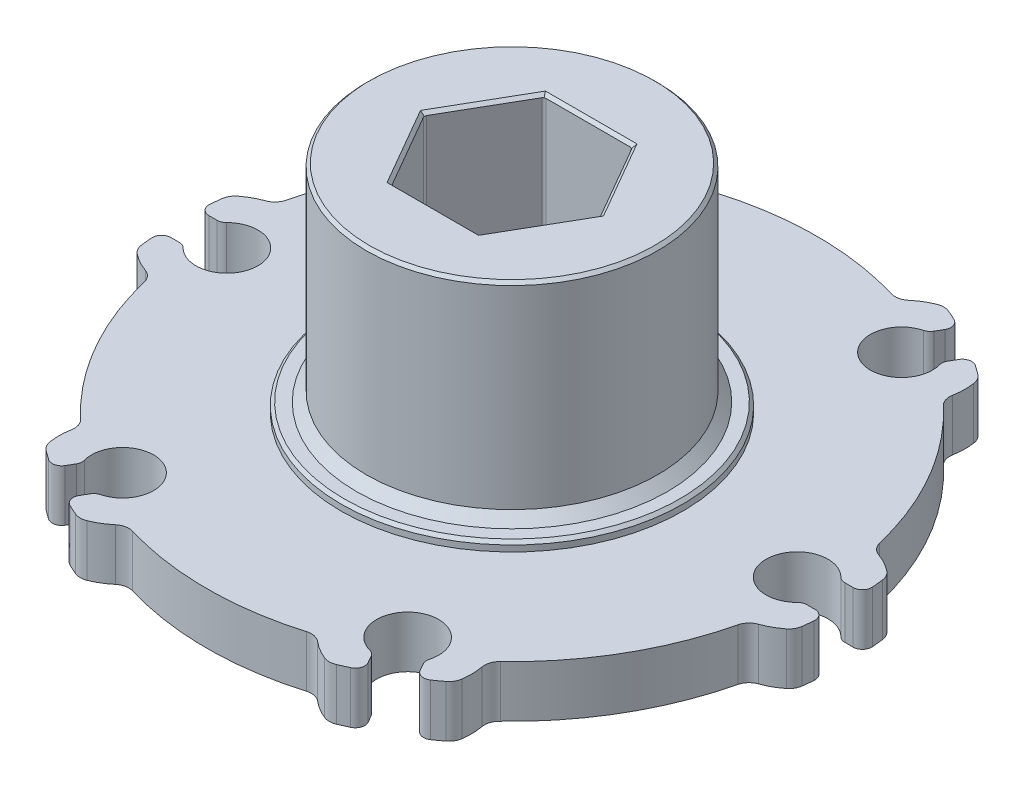
from build123d import *

# Parameters (mm, degrees)
SKETCH1_W           = 27.7876
SKETCH1_H           = 4.318
CUT_EXTRUDE1_DEPTH  = 5.318
CUT_EXTRUDE2_DEPTH  = 5.318
CUT_EXTRUDE3_DEPTH  = 5.318
CUT_EXTRUDE4_DEPTH  = 5.318
CUT_EXTRUDE5_DEPTH  = 5.318
CUT_EXTRUDE6_DEPTH  = 5.318
CUT_EXTRUDE7_DEPTH  = 5.318
CUT_EXTRUDE8_DEPTH  = 5.318
CUT_EXTRUDE9_DEPTH  = 5.318
CUT_EXTRUDE10_DEPTH = 5.318
CUT_EXTRUDE11_DEPTH = 5.318
CUT_EXTRUDE12_DEPTH = 5.318
SKETCH14_R          = 14.2748
BOSS_EXTRUDE1_DEPTH = 1.524
SKETCH15_R          = 9.23823544
BOSS_EXTRUDE2_DEPTH = 1.524
SKETCH16_R          = 14.2748
BOSS_EXTRUDE3_DEPTH = 0.762
SKETCH17_R          = 12.1666
BOSS_EXTRUDE4_DEPTH = 17.272
CUT_EXTRUDE13_DEPTH = 26.4
SKETCH19_W          = 2.5908
SKETCH19_H          = 4.318
SKETCH20_W          = 2.5908
SKETCH20_H          = 4.318
SKETCH21_W          = 2.5908
SKETCH21_H          = 4.318
SKETCH22_W          = 2.5908
SKETCH22_H          = 4.318
SKETCH23_W          = 2.5908
SKETCH23_H          = 4.318
SKETCH24_W          = 2.5908
SKETCH24_H          = 4.318
CHAMFER1_SIZE       = 0.254
CHAMFER2_SIZE       = 0.8128
FILLET1_R           = 0.254
FILLET2_R           = 0.7874
FILLET3_R           = 1.27


with BuildPart() as part:
    # Sketch1 → Revolve1 (revolve)
    with BuildSketch(Plane.XY):
        with Locations((13.8938, 5.207)):
            Rectangle(SKETCH1_W, SKETCH1_H)
    revolve(axis=Axis((0, 7.366, 0), (0, -1, 0)))

    # Sketch2 → Cut-Extrude1 (cut, through all)
    with BuildSketch(Plane(origin=(0, 7.366, 0), x_dir=(-1, 0, 0), z_dir=(0, 1, 0))):
        with BuildLine():
            Line((27.742216161, 1.5875), (25.859959008, 1.5875))
            ThreePointArc((25.859959008, 1.5875), (26.4033, 0), (25.859959008, -1.5875))
            Line((25.859959008, -1.5875), (27.742216161, -1.5875))
            ThreePointArc((27.742216161, -1.5875), (27.7876, 0), (27.742216161, 1.5875))
        make_face()
    extrude(amount=-CUT_EXTRUDE1_DEPTH, mode=Mode.SUBTRACT)

    # Sketch3 → Cut-Extrude2 (cut, through all)
    with BuildSketch(Plane(origin=(0, 7.366, 0), x_dir=(-1, 0, 0), z_dir=(0, 1, 0))):
        with BuildLine():
            ThreePointArc((27.521980347, -3.832924674), (26.332306318, -4.701290474), (24.95050128, -5.211190755))
            ThreePointArc((24.95050128, -5.211190755), (22.074034915, -12.74445), (16.988274218, -19.002172568))
            ThreePointArc((16.988274218, -19.002172568), (17.23759014, -20.453800974), (17.080400312, -21.918271806))
            ThreePointArc((17.080400312, -21.918271806), (24.06476751, -13.8938), (27.521980347, -3.832924674))
        make_face()
    extrude(amount=-CUT_EXTRUDE2_DEPTH, mode=Mode.SUBTRACT)

    # Sketch4 → Cut-Extrude3 (cut, through all)
    with BuildSketch(Plane(origin=(0, 7.366, 0), x_dir=(-1, 0, 0), z_dir=(0, 1, 0))):
        with BuildLine():
            Line((15.245923409, -23.231713952), (14.304794833, -21.601631442))
            ThreePointArc((14.304794833, -21.601631442), (13.20165, -22.865928544), (11.555164176, -23.189131442))
            Line((11.555164176, -23.189131442), (12.496292752, -24.819213952))
            ThreePointArc((12.496292752, -24.819213952), (13.8938, -24.06476751), (15.245923409, -23.231713952))
        make_face()
    extrude(amount=-CUT_EXTRUDE3_DEPTH, mode=Mode.SUBTRACT)

    # Sketch5 → Cut-Extrude4 (cut, through all)
    with BuildSketch(Plane(origin=(0, 7.366, 0), x_dir=(-1, 0, 0), z_dir=(0, 1, 0))):
        with BuildLine():
            ThreePointArc((10.441580035, -25.75119648), (9.094716178, -25.155091448), (7.962227062, -24.213363323))
            ThreePointArc((7.962227062, -24.213363323), (0, -25.4889), (-7.962227062, -24.213363323))
            ThreePointArc((-7.962227062, -24.213363323), (-9.094716178, -25.155091448), (-10.441580035, -25.75119648))
            ThreePointArc((-10.441580035, -25.75119648), (0, -27.7876), (10.441580035, -25.75119648))
        make_face()
    extrude(amount=-CUT_EXTRUDE4_DEPTH, mode=Mode.SUBTRACT)

    # Sketch6 → Cut-Extrude5 (cut, through all)
    with BuildSketch(Plane(origin=(0, 7.366, 0), x_dir=(-1, 0, 0), z_dir=(0, 1, 0))):
        with BuildLine():
            Line((-12.496292752, -24.819213952), (-11.555164176, -23.189131442))
            ThreePointArc((-11.555164176, -23.189131442), (-13.20165, -22.865928544), (-14.304794833, -21.601631442))
            Line((-14.304794833, -21.601631442), (-15.245923409, -23.231713952))
            ThreePointArc((-15.245923409, -23.231713952), (-13.8938, -24.06476751), (-12.496292752, -24.819213952))
        make_face()
    extrude(amount=-CUT_EXTRUDE5_DEPTH, mode=Mode.SUBTRACT)

    # Sketch7 → Cut-Extrude6 (cut, through all)
    with BuildSketch(Plane(origin=(0, 7.366, 0), x_dir=(-1, 0, 0), z_dir=(0, 1, 0))):
        with BuildLine():
            ThreePointArc((-17.080400312, -21.918271806), (-17.23759014, -20.453800974), (-16.988274218, -19.002172568))
            ThreePointArc((-16.988274218, -19.002172568), (-22.074034915, -12.74445), (-24.95050128, -5.211190755))
            ThreePointArc((-24.95050128, -5.211190755), (-26.332306318, -4.701290474), (-27.521980347, -3.832924674))
            ThreePointArc((-27.521980347, -3.832924674), (-24.06476751, -13.8938), (-17.080400312, -21.918271806))
        make_face()
    extrude(amount=-CUT_EXTRUDE6_DEPTH, mode=Mode.SUBTRACT)

    # Sketch8 → Cut-Extrude7 (cut, through all)
    with BuildSketch(Plane(origin=(0, 7.366, 0), x_dir=(-1, 0, 0), z_dir=(0, 1, 0))):
        with BuildLine():
            Line((-27.742216161, -1.5875), (-25.859959008, -1.5875))
            ThreePointArc((-25.859959008, -1.5875), (-26.4033, 0), (-25.859959008, 1.5875))
            Line((-25.859959008, 1.5875), (-27.742216161, 1.5875))
            ThreePointArc((-27.742216161, 1.5875), (-27.7876, 0), (-27.742216161, -1.5875))
        make_face()
    extrude(amount=-CUT_EXTRUDE7_DEPTH, mode=Mode.SUBTRACT)

    # Sketch9 → Cut-Extrude8 (cut, through all)
    with BuildSketch(Plane(origin=(0, 7.366, 0), x_dir=(-1, 0, 0), z_dir=(0, 1, 0))):
        with BuildLine():
            ThreePointArc((-27.521980347, 3.832924674), (-26.332306318, 4.701290474), (-24.95050128, 5.211190755))
            ThreePointArc((-24.95050128, 5.211190755), (-22.074034915, 12.74445), (-16.988274218, 19.002172568))
            ThreePointArc((-16.988274218, 19.002172568), (-17.23759014, 20.453800974), (-17.080400312, 21.918271806))
            ThreePointArc((-17.080400312, 21.918271806), (-24.06476751, 13.8938), (-27.521980347, 3.832924674))
        make_face()
    extrude(amount=-CUT_EXTRUDE8_DEPTH, mode=Mode.SUBTRACT)

    # Sketch10 → Cut-Extrude9 (cut, through all)
    with BuildSketch(Plane(origin=(0, 7.366, 0), x_dir=(-1, 0, 0), z_dir=(0, 1, 0))):
        with BuildLine():
            Line((-15.245923409, 23.231713952), (-14.304794833, 21.601631442))
            ThreePointArc((-14.304794833, 21.601631442), (-13.20165, 22.865928544), (-11.555164176, 23.189131442))
            Line((-11.555164176, 23.189131442), (-12.496292752, 24.819213952))
            ThreePointArc((-12.496292752, 24.819213952), (-13.8938, 24.06476751), (-15.245923409, 23.231713952))
        make_face()
    extrude(amount=-CUT_EXTRUDE9_DEPTH, mode=Mode.SUBTRACT)

    # Sketch11 → Cut-Extrude10 (cut, through all)
    with BuildSketch(Plane(origin=(0, 7.366, 0), x_dir=(-1, 0, 0), z_dir=(0, 1, 0))):
        with BuildLine():
            ThreePointArc((-10.441580035, 25.75119648), (-9.094716178, 25.155091448), (-7.962227062, 24.213363323))
            ThreePointArc((-7.962227062, 24.213363323), (0, 25.4889), (7.962227062, 24.213363323))
            ThreePointArc((7.962227062, 24.213363323), (9.094716178, 25.155091448), (10.441580035, 25.75119648))
            ThreePointArc((10.441580035, 25.75119648), (0, 27.7876), (-10.441580035, 25.75119648))
        make_face()
    extrude(amount=-CUT_EXTRUDE10_DEPTH, mode=Mode.SUBTRACT)

    # Sketch12 → Cut-Extrude11 (cut, through all)
    with BuildSketch(Plane(origin=(0, 7.366, 0), x_dir=(-1, 0, 0), z_dir=(0, 1, 0))):
        with BuildLine():
            Line((12.496292752, 24.819213952), (11.555164176, 23.189131442))
            ThreePointArc((11.555164176, 23.189131442), (13.20165, 22.865928544), (14.304794833, 21.601631442))
            Line((14.304794833, 21.601631442), (15.245923409, 23.231713952))
            ThreePointArc((15.245923409, 23.231713952), (13.8938, 24.06476751), (12.496292752, 24.819213952))
        make_face()
    extrude(amount=-CUT_EXTRUDE11_DEPTH, mode=Mode.SUBTRACT)

    # Sketch13 → Cut-Extrude12 (cut, through all)
    with BuildSketch(Plane(origin=(0, 7.366, 0), x_dir=(-1, 0, 0), z_dir=(0, 1, 0))):
        with BuildLine():
            ThreePointArc((17.080400312, 21.918271806), (17.23759014, 20.453800974), (16.988274218, 19.002172568))
            ThreePointArc((16.988274218, 19.002172568), (22.074034915, 12.74445), (24.95050128, 5.211190755))
            ThreePointArc((24.95050128, 5.211190755), (26.332306318, 4.701290474), (27.521980347, 3.832924674))
            ThreePointArc((27.521980347, 3.832924674), (24.06476751, 13.8938), (17.080400312, 21.918271806))
        make_face()
    extrude(amount=-CUT_EXTRUDE12_DEPTH, mode=Mode.SUBTRACT)

    # Sketch14 → Boss-Extrude1 (add)
    with BuildSketch(Plane.XZ.offset(-3.048)):
        Circle(SKETCH14_R)
    extrude(amount=BOSS_EXTRUDE1_DEPTH)

    # Sketch15 → Boss-Extrude2 (add)
    with BuildSketch(Plane.XZ.offset(-1.524)):
        Circle(SKETCH15_R)
    extrude(amount=BOSS_EXTRUDE2_DEPTH)

    # Sketch16 → Boss-Extrude3 (add)
    with BuildSketch(Plane(origin=(0, 7.366, 0), x_dir=(-1, 0, 0), z_dir=(0, 1, 0))):
        Circle(SKETCH16_R)
    extrude(amount=BOSS_EXTRUDE3_DEPTH)

    # Sketch17 → Boss-Extrude4 (add)
    with BuildSketch(Plane(origin=(0, 8.128, 0), x_dir=(-1, 0, 0), z_dir=(0, 1, 0))):
        Circle(SKETCH17_R)
    extrude(amount=BOSS_EXTRUDE4_DEPTH)

    # Sketch18 → Cut-Extrude13 (cut, through all)
    with BuildSketch(Plane(origin=(0, 25.4, 0), x_dir=(-1, 0, 0), z_dir=(0, 1, 0))):
        Polygon((-3.673506558, -6.3627), (3.673506558, -6.3627), (7.347013116, 0), (3.673506558, 6.3627), (-3.673506558, 6.3627), (-7.347013116, 0), align=None)
    extrude(amount=-CUT_EXTRUDE13_DEPTH, mode=Mode.SUBTRACT)

    # Sketch19 → Cut-Revolve1 (revolve, cut)
    with BuildSketch(Plane(origin=(0, 0, 0), x_dir=(-1, 0, 0), z_dir=(0, 0, -1))):
        with Locations((22.5171, 5.207)):
            Rectangle(SKETCH19_W, SKETCH19_H)
    revolve(axis=Axis((-23.8125, 3.048, 0), (0, 1, 0)), mode=Mode.SUBTRACT)

    # Sketch20 → Cut-Revolve2 (revolve, cut)
    with BuildSketch(Plane(origin=(0, 0, -20.622229928), x_dir=(-1, 0, 0), z_dir=(0, 0, -1))):
        with Locations((10.61085, 5.207)):
            Rectangle(SKETCH20_W, SKETCH20_H)
    revolve(axis=Axis((-11.90625, 3.048, -20.622229928), (0, 1, 0)), mode=Mode.SUBTRACT)

    # Sketch21 → Cut-Revolve3 (revolve, cut)
    with BuildSketch(Plane(origin=(0, 0, -20.622229928), x_dir=(-1, 0, 0), z_dir=(0, 0, -1))):
        with Locations((-13.20165, 5.207)):
            Rectangle(SKETCH21_W, SKETCH21_H)
    revolve(axis=Axis((11.90625, 3.048, -20.622229928), (0, 1, 0)), mode=Mode.SUBTRACT)

    # Sketch22 → Cut-Revolve4 (revolve, cut)
    with BuildSketch(Plane(origin=(0, 0, 0), x_dir=(-1, 0, 0), z_dir=(0, 0, -1))):
        with Locations((-25.1079, 5.207)):
            Rectangle(SKETCH22_W, SKETCH22_H)
    revolve(axis=Axis((23.8125, 3.048, 0), (0, 1, 0)), mode=Mode.SUBTRACT)

    # Sketch23 → Cut-Revolve5 (revolve, cut)
    with BuildSketch(Plane(origin=(0, 0, 20.622229928), x_dir=(-1, 0, 0), z_dir=(0, 0, -1))):
        with Locations((-13.20165, 5.207)):
            Rectangle(SKETCH23_W, SKETCH23_H)
    revolve(axis=Axis((11.90625, 3.048, 20.622229928), (0, 1, 0)), mode=Mode.SUBTRACT)

    # Sketch24 → Cut-Revolve6 (revolve, cut)
    with BuildSketch(Plane(origin=(0, 0, 20.622229928), x_dir=(-1, 0, 0), z_dir=(0, 0, -1))):
        with Locations((10.61085, 5.207)):
            Rectangle(SKETCH24_W, SKETCH24_H)
    revolve(axis=Axis((-11.90625, 3.048, 20.622229928), (0, 1, 0)), mode=Mode.SUBTRACT)

    # Chamfer1
    chamfer1_edges = [part.edges().sort_by_distance(p)[0] for p in [
        (-14.2748, 1.524, 0),
        (-9.23823544, 0, 0),
        (14.2748, 8.128, 0),
        (12.1666, 25.4, 0),
        (5.510259837, 0, -3.18135),
        (5.510259837, 0, 3.18135),
        (0, 0, 6.3627),
        (-5.510259837, 0, 3.18135),
        (-5.510259837, 0, -3.18135),
        (0, 0, -6.3627),
        (5.510259837, 25.4, -3.18135),
        (0, 25.4, -6.3627),
        (-5.510259837, 25.4, -3.18135),
        (-5.510259837, 25.4, 3.18135),
        (0, 25.4, 6.3627),
        (5.510259837, 25.4, 3.18135),
    ]]
    chamfer(chamfer1_edges, length=CHAMFER1_SIZE)

    # Chamfer2
    chamfer2_edges = [part.edges().sort_by_distance(p)[0] for p in [
        (12.1666, 8.128, 0),
    ]]
    chamfer(chamfer2_edges, length=CHAMFER2_SIZE)

    # Fillet1
    fillet1_edges = [part.edges().sort_by_distance(p)[0] for p in [
        (3.673506558, 12.7, -6.3627),
        (7.347013116, 12.7, 0),
        (-3.673506558, 12.7, -6.3627),
        (-7.347013116, 12.7, 0),
        (-3.673506558, 12.7, 6.3627),
        (3.673506558, 12.7, 6.3627),
    ]]
    fillet(fillet1_edges, radius=FILLET1_R)

    # Fillet2
    fillet2_edges = [part.edges().sort_by_distance(p)[0] for p in [
        (27.742216161, 5.207, -1.5875),
        (27.742216161, 5.207, 1.5875),
        (25.859959008, 5.207, 1.5875),
        (25.859959008, 5.207, -1.5875),
        (-27.742216161, 5.207, 1.5875),
        (-27.742216161, 5.207, -1.5875),
        (-25.859959008, 5.207, -1.5875),
        (-25.859959008, 5.207, 1.5875),
        (15.245923409, 5.207, 23.231713952),
        (12.496292752, 5.207, 24.819213952),
        (11.555164176, 5.207, 23.189131442),
        (14.304794833, 5.207, 21.601631442),
        (-12.496292752, 5.207, 24.819213952),
        (-15.245923409, 5.207, 23.231713952),
        (-14.304794833, 5.207, 21.601631442),
        (-11.555164176, 5.207, 23.189131442),
        (-15.245923409, 5.207, -23.231713952),
        (-12.496292752, 5.207, -24.819213952),
        (-11.555164176, 5.207, -23.189131442),
        (-14.304794833, 5.207, -21.601631442),
        (12.496292752, 5.207, -24.819213952),
        (15.245923409, 5.207, -23.231713952),
        (14.304794833, 5.207, -21.601631442),
        (11.555164176, 5.207, -23.189131442),
    ]]
    fillet(fillet2_edges, radius=FILLET2_R)

    # Fillet3
    fillet3_edges = [part.edges().sort_by_distance(p)[0] for p in [
        (27.521980347, 5.207, 3.832924674),
        (17.080400312, 5.207, 21.918271806),
        (16.988274218, 5.207, 19.002172568),
        (24.95050128, 5.207, 5.211190755),
        (10.441580035, 5.207, 25.75119648),
        (-10.441580035, 5.207, 25.75119648),
        (-7.962227062, 5.207, 24.213363323),
        (7.962227062, 5.207, 24.213363323),
        (-17.080400312, 5.207, 21.918271806),
        (-27.521980347, 5.207, 3.832924674),
        (-24.95050128, 5.207, 5.211190755),
        (-16.988274218, 5.207, 19.002172568),
        (-27.521980347, 5.207, -3.832924674),
        (-17.080400312, 5.207, -21.918271806),
        (-16.988274218, 5.207, -19.002172568),
        (-24.95050128, 5.207, -5.211190755),
        (-10.441580035, 5.207, -25.75119648),
        (10.441580035, 5.207, -25.75119648),
        (7.962227062, 5.207, -24.213363323),
        (-7.962227062, 5.207, -24.213363323),
        (17.080400312, 5.207, -21.918271806),
        (27.521980347, 5.207, -3.832924674),
        (24.95050128, 5.207, -5.211190755),
        (16.988274218, 5.207, -19.002172568),
    ]]
    fillet(fillet3_edges, radius=FILLET3_R)


solid = part.part
